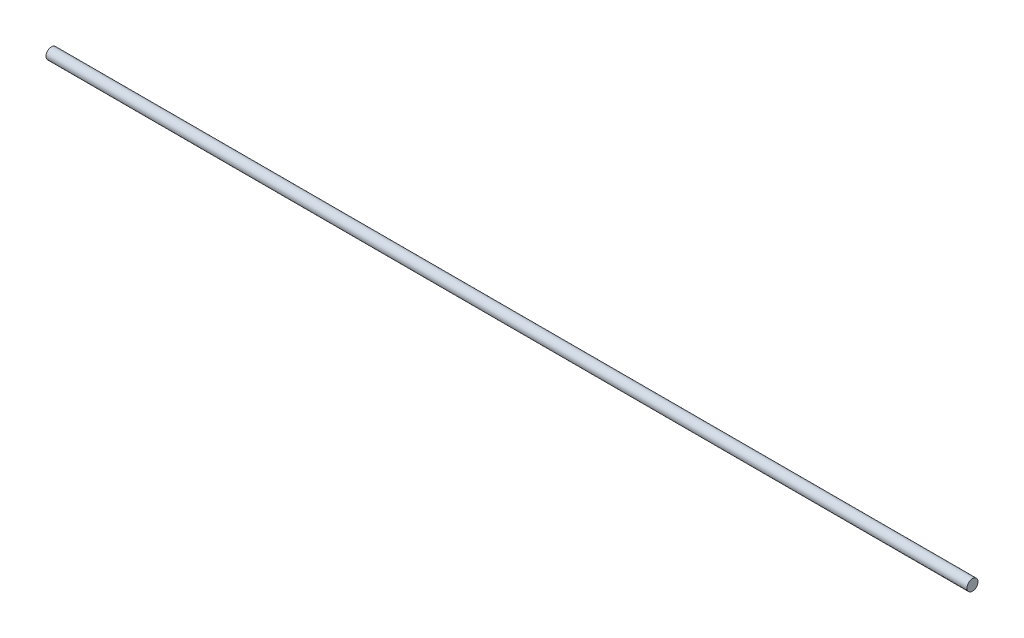
from build123d import *

# Parameters (mm, degrees)
SKETCH1_R           = 1.651
BOSS_EXTRUDE1_DEPTH = 276.225


with BuildPart() as part:
    # Sketch1 → Boss-Extrude1 (new body)
    with BuildSketch(Plane(origin=(0, 0, 0), x_dir=(0, 0, -1), z_dir=(1, 0, 0))):
        Circle(SKETCH1_R)
    extrude(amount=BOSS_EXTRUDE1_DEPTH)


solid = part.part
